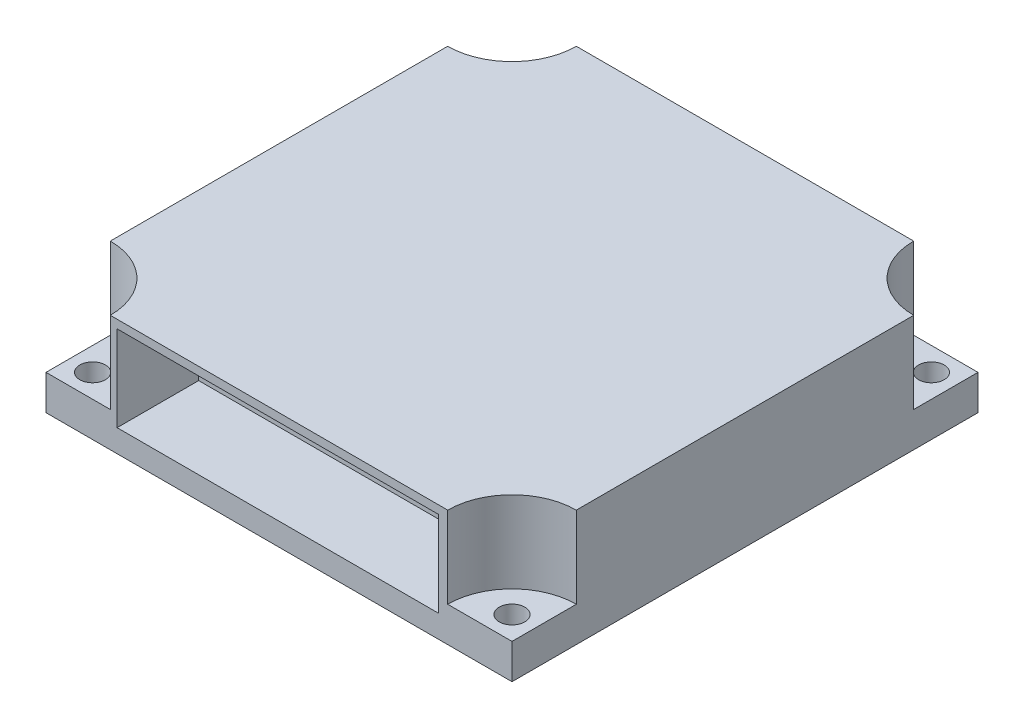
from build123d import *

# Parameters (mm, degrees)
SKETCH1_W           = 40
SKETCH1_H           = 40
SKETCH1_R           = 1.1
BOSS_EXTRUDE1_DEPTH = 10
CUT_EXTRUDE1_DEPTH  = 7
SKETCH3_W           = 27.571173344
SKETCH3_H           = 7.347922722
CUT_EXTRUDE2_DEPTH  = 7


with BuildPart() as part:
    # Sketch1 → Boss-Extrude1 (new body)
    with BuildSketch(Plane(origin=(0, 0, 0), x_dir=(1, 0, 0), z_dir=(0, 1, 0))):
        with Locations((20, 20)):
            Rectangle(SKETCH1_W, SKETCH1_H)
        with Locations((2, 38)):
            Circle(SKETCH1_R, mode=Mode.SUBTRACT)
        with Locations((38, 38)):
            Circle(SKETCH1_R, mode=Mode.SUBTRACT)
        with Locations((2, 2)):
            Circle(SKETCH1_R, mode=Mode.SUBTRACT)
        with Locations((38, 2)):
            Circle(SKETCH1_R, mode=Mode.SUBTRACT)
    extrude(amount=BOSS_EXTRUDE1_DEPTH)

    # Sketch2 → Cut-Extrude1 (cut)
    with BuildSketch(Plane(origin=(0, 10, 0), x_dir=(1, 0, 0), z_dir=(0, 1, 0))):
        with BuildLine():
            Line((0, 0), (5.519280972, 0))
            ThreePointArc((5.519280972, 0), (3.902721002, 3.902721002), (0, 5.519280972))
            Line((0, 5.519280972), (0, 0))
        make_face()
        with BuildLine():
            Line((40, 0), (40, 5.519280972))
            ThreePointArc((40, 5.519280972), (36.097278998, 3.902721002), (34.480719028, 0))
            Line((34.480719028, 0), (40, 0))
        make_face()
        with BuildLine():
            Line((40, 40), (34.480719028, 40))
            ThreePointArc((34.480719028, 40), (36.097278998, 36.097278998), (40, 34.480719028))
            Line((40, 34.480719028), (40, 40))
        make_face()
        with BuildLine():
            Line((0, 40), (0, 34.480719028))
            ThreePointArc((0, 34.480719028), (3.902721002, 36.097278998), (5.519280972, 40))
            Line((5.519280972, 40), (0, 40))
        make_face()
    extrude(amount=-CUT_EXTRUDE1_DEPTH, mode=Mode.SUBTRACT)

    # Sketch3 → Cut-Extrude2 (cut)
    with BuildSketch(Plane.XY):
        with Locations((19.889703926, 5.612775806)):
            Rectangle(SKETCH3_W, SKETCH3_H)
    extrude(amount=-CUT_EXTRUDE2_DEPTH, mode=Mode.SUBTRACT)


solid = part.part
